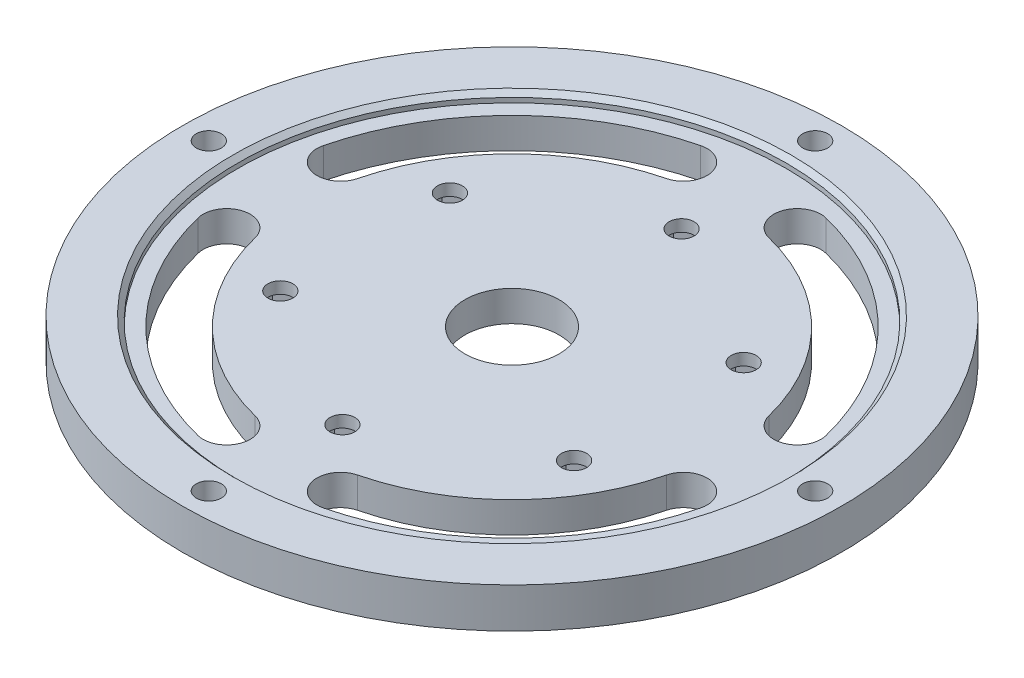
from build123d import *

# Parameters (mm, degrees)
SKETCH1_R           = 70
BOSS_EXTRUDE1_DEPTH = 6.5
SKETCH2_R           = 2.65
CUT_EXTRUDE1_DEPTH  = 7.5
SKETCH3_R           = 70
SKETCH3_R_2         = 58.25
SKETCH3_R_3         = 2.65
BOSS_EXTRUDE2_DEPTH = 2
CUT_EXTRUDE2_DEPTH  = 7.5
SKETCH5_R           = 2.65
CUT_EXTRUDE3_DEPTH  = 7.5
CUT_EXTRUDE4_DEPTH  = 4
SKETCH7_R           = 10
CUT_EXTRUDE5_DEPTH  = 7.5
CHAMFER1_SIZE       = 1
SKETCH8_R           = 4.35
CUT_EXTRUDE6_DEPTH  = 4


with BuildPart() as part:
    # Sketch1 → Boss-Extrude1 (new body)
    with BuildSketch(Plane(origin=(0, 0, 0), x_dir=(1, 0, 0), z_dir=(0, 1, 0))):
        Circle(SKETCH1_R)
    extrude(amount=BOSS_EXTRUDE1_DEPTH)

    # Sketch2 → Cut-Extrude1 (cut, through all)
    with BuildSketch(Plane(origin=(0, 6.5, 0), x_dir=(1, 0, 0), z_dir=(0, 1, 0))):
        with Locations((0, 64.4)):
            Circle(SKETCH2_R)
        with Locations((64.4, 0)):
            Circle(SKETCH2_R)
        with Locations((0, -64.4)):
            Circle(SKETCH2_R)
        with Locations((-64.4, 0)):
            Circle(SKETCH2_R)
    extrude(amount=-CUT_EXTRUDE1_DEPTH, mode=Mode.SUBTRACT)

    # Sketch3 → Boss-Extrude2 (add)
    with BuildSketch(Plane(origin=(0, 6.5, 0), x_dir=(1, 0, 0), z_dir=(0, 1, 0))):
        Circle(SKETCH3_R)
        Circle(SKETCH3_R_2, mode=Mode.SUBTRACT)
        with Locations((-64.4, 0)):
            Circle(SKETCH3_R_3, mode=Mode.SUBTRACT)
        with Locations((0, 64.4)):
            Circle(SKETCH3_R_3, mode=Mode.SUBTRACT)
        with Locations((64.4, 0)):
            Circle(SKETCH3_R_3, mode=Mode.SUBTRACT)
        with Locations((0, -64.4)):
            Circle(SKETCH3_R_3, mode=Mode.SUBTRACT)
    extrude(amount=BOSS_EXTRUDE2_DEPTH)

    # Sketch4 → Cut-Extrude2 (cut, through all)
    with BuildSketch(Plane(origin=(0, 6.5, 0), x_dir=(1, 0, 0), z_dir=(0, 1, 0))):
        with BuildLine():
            ThreePointArc((-13.305704258, 53.366264945), (-38.890872965, 38.890872965), (-53.366264945, 13.305704258))
            ThreePointArc((-53.366264945, 13.305704258), (-49.724395792, 7.244616149), (-43.663307682, 10.886485302))
            ThreePointArc((-43.663307682, 10.886485302), (-31.819805153, 31.819805153), (-10.886485302, 43.663307682))
            ThreePointArc((-10.886485302, 43.663307682), (-7.244616149, 49.724395792), (-13.305704258, 53.366264945))
        make_face()
        with BuildLine():
            ThreePointArc((43.663307682, 10.886485302), (31.819805153, 31.819805153), (10.886485302, 43.663307682))
            ThreePointArc((10.886485302, 43.663307682), (7.244616149, 49.724395792), (13.305704258, 53.366264945))
            ThreePointArc((13.305704258, 53.366264945), (38.890872965, 38.890872965), (53.366264945, 13.305704258))
            ThreePointArc((53.366264945, 13.305704258), (49.724395792, 7.244616149), (43.663307682, 10.886485302))
        make_face()
        with BuildLine():
            ThreePointArc((10.886485302, -43.663307682), (31.819805153, -31.819805153), (43.663307682, -10.886485302))
            ThreePointArc((43.663307682, -10.886485302), (49.724395792, -7.244616149), (53.366264945, -13.305704258))
            ThreePointArc((53.366264945, -13.305704258), (38.890872965, -38.890872965), (13.305704258, -53.366264945))
            ThreePointArc((13.305704258, -53.366264945), (7.244616149, -49.724395792), (10.886485302, -43.663307682))
        make_face()
        with BuildLine():
            ThreePointArc((-43.663307682, -10.886485302), (-31.819805153, -31.819805153), (-10.886485302, -43.663307682))
            ThreePointArc((-10.886485302, -43.663307682), (-7.244616149, -49.724395792), (-13.305704258, -53.366264945))
            ThreePointArc((-13.305704258, -53.366264945), (-38.890872965, -38.890872965), (-53.366264945, -13.305704258))
            ThreePointArc((-53.366264945, -13.305704258), (-49.724395792, -7.244616149), (-43.663307682, -10.886485302))
        make_face()
    extrude(amount=-CUT_EXTRUDE2_DEPTH, mode=Mode.SUBTRACT)

    # Sketch5 → Cut-Extrude3 (cut, through all)
    with BuildSketch(Plane(origin=(0, 6.5, 0), x_dir=(1, 0, 0), z_dir=(0, 1, 0))):
        with Locations((0, 36.02147888)):
            Circle(SKETCH5_R)
        with Locations((31.195515792, 18.01073944)):
            Circle(SKETCH5_R)
        with Locations((31.195515792, -18.01073944)):
            Circle(SKETCH5_R)
        with Locations((0, -36.02147888)):
            Circle(SKETCH5_R)
        with Locations((-31.195515792, -18.01073944)):
            Circle(SKETCH5_R)
        with Locations((-31.195515792, 18.01073944)):
            Circle(SKETCH5_R)
    extrude(amount=-CUT_EXTRUDE3_DEPTH, mode=Mode.SUBTRACT)

    # Sketch6 → Cut-Extrude4 (cut)
    with BuildSketch(Plane.XZ):
        Polygon((27.195515792, -20.320140517), (31.195515792, -22.629541594), (35.195515792, -20.320140517), (35.195515792, -15.701338363), (31.195515792, -13.391937286), (27.195515792, -15.701338363), align=None)
        Polygon((-4, -33.712077803), (-4, -38.330879957), (0, -40.640281034), (4, -38.330879957), (4, -33.712077803), (0, -31.402676726), align=None)
        Polygon((-31.195515792, -13.391937286), (-35.195515792, -15.701338363), (-35.195515792, -20.320140517), (-31.195515792, -22.629541594), (-27.195515792, -20.320140517), (-27.195515792, -15.701338363), align=None)
        Polygon((-27.195515792, 20.320140517), (-31.195515792, 22.629541594), (-35.195515792, 20.320140517), (-35.195515792, 15.701338363), (-31.195515792, 13.391937286), (-27.195515792, 15.701338363), align=None)
        Polygon((4, 33.712077803), (4, 38.330879957), (0, 40.640281034), (-4, 38.330879957), (-4, 33.712077803), (0, 31.402676726), align=None)
        Polygon((31.195515792, 13.391937286), (35.195515792, 15.701338363), (35.195515792, 20.320140517), (31.195515792, 22.629541594), (27.195515792, 20.320140517), (27.195515792, 15.701338363), align=None)
    extrude(amount=-CUT_EXTRUDE4_DEPTH, mode=Mode.SUBTRACT)

    # Sketch7 → Cut-Extrude5 (cut, through all)
    with BuildSketch(Plane(origin=(0, 6.5, 0), x_dir=(1, 0, 0), z_dir=(0, 1, 0))):
        Circle(SKETCH7_R)
    extrude(amount=-CUT_EXTRUDE5_DEPTH, mode=Mode.SUBTRACT)

    # Chamfer1
    chamfer1_edges = [part.edges().sort_by_distance(p)[0] for p in [
        (-58.25, 8.5, 0),
    ]]
    chamfer(chamfer1_edges, length=CHAMFER1_SIZE)

    # Sketch8 → Cut-Extrude6 (cut)
    with BuildSketch(Plane.XZ):
        with Locations((-64.4, 0)):
            Circle(SKETCH8_R)
        with Locations((0, 64.4)):
            Circle(SKETCH8_R)
        with Locations((64.4, 0)):
            Circle(SKETCH8_R)
        with Locations((0, -64.4)):
            Circle(SKETCH8_R)
    extrude(amount=-CUT_EXTRUDE6_DEPTH, mode=Mode.SUBTRACT)


solid = part.part
